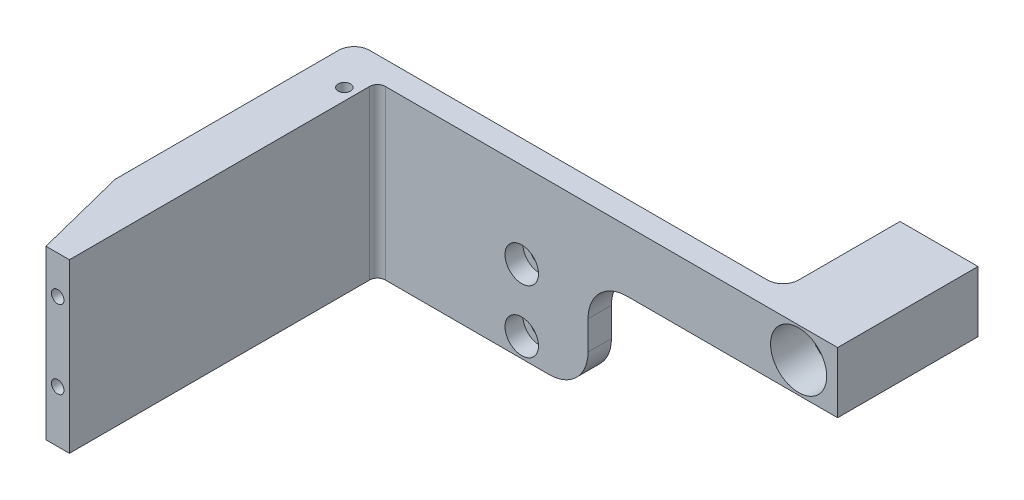
from build123d import *

# Parameters (mm, degrees)
SKETCH_1_W                = 40
SKETCH_1_H                = 10
EXTRUDE_1_DEPTH           = 3
SKETCH_2_W                = 3
SKETCH_2_H                = 10
EXTRUDE_2_DEPTH           = 39.5
EXTRUDE_3_DEPTH           = 10
FILLET_1_R                = 1
SKETCH_4_W                = 40
SKETCH_4_H                = 3
EXTRUDE_4_DEPTH           = 10
HOLE_WIZARD_1_D           = 2.4
HOLE_WIZARD_1_DEPTH       = 3.2
HOLE_WIZARD_1_CBORE_D     = 4.3
HOLE_WIZARD_1_CBORE_DEPTH = 2.3
HOLE_WIZARD_1_TIP         = 0.721032743
HOLE_WIZARD_M2_1_D        = 1.6
HOLE_WIZARD_M2_1_DEPTH    = 5.2
HOLE_WIZARD_M2_1_TIP      = 0.480688495
SKETCH_13_W               = 40
SKETCH_13_H               = 8.5
CUT_EXTRUDE_2_DEPTH       = 10
EXTRUDE_7_DEPTH           = 10
SKETCH_17_W               = 9.259373991
SKETCH_17_H               = 43.053569651
CUT_EXTRUDE_3_DEPTH       = 20
SKETCH_14_W               = 3
SKETCH_14_H               = 7.8
EXTRUDE_8_DEPTH           = 32
SKETCH_18_W               = 10
SKETCH_18_H               = 7.8
EXTRUDE_9_DEPTH           = 15
SKETCH_19_R               = 3.6
CUT_EXTRUDE_4_DEPTH       = 5
HOLE_WIZARD_M4_1_D        = 3.3
FILLET_2_R                = 2
EXTRUDE_10_DEPTH          = 10
EXTRUDE_11_DEPTH          = 1.5
HOLE_WIZARD_M2_2_D        = 1.6
HOLE_WIZARD_M2_2_DEPTH    = 5.2
HOLE_WIZARD_M2_2_TIP      = 0.480688495
HOLE_WIZARD_M2_3_D        = 1.6
HOLE_WIZARD_M2_3_DEPTH    = 5.2
HOLE_WIZARD_M2_3_TIP      = 0.480688495
HOLE_WIZARD_M2_4_D        = 1.6
HOLE_WIZARD_M2_4_DEPTH    = 5.2
HOLE_WIZARD_M2_4_TIP      = 0.480688495
FILLET_3_R                = 2
FILLET_4_R                = 5


with BuildPart() as part:
    # 草图1 → 凸台-拉伸1 (new body)
    with BuildSketch(Plane.XY):
        Rectangle(SKETCH_1_W, SKETCH_1_H)
    extrude(amount=EXTRUDE_1_DEPTH)

    # 草图2 → 凸台-拉伸2 (add)
    with BuildSketch(Plane.XY.offset(3)):
        with Locations((-8.5, 0)):
            Rectangle(SKETCH_2_W, SKETCH_2_H)
    extrude(amount=EXTRUDE_2_DEPTH)

    # 草图3 → 凸台-拉伸3 (add)
    with BuildSketch(Plane(origin=(0, 5, 0), x_dir=(1, 0, 0), z_dir=(0, 1, 0))):
        Polygon((-20, -3), (-10, -42.5), (-10, -30.276150361), (-16.905354522, -3), align=None)
    extrude(amount=-EXTRUDE_3_DEPTH)

    # 圆角1
    fillet_1_edges = [part.edges().sort_by_distance(p)[0] for p in [
        (-7, 0, 3),
    ]]
    fillet(fillet_1_edges, radius=FILLET_1_R)

    # 草图4 → 凸台-拉伸4 (add)
    with BuildSketch(Plane(origin=(0, 5, 0), x_dir=(1, 0, 0), z_dir=(0, 1, 0))):
        with Locations((0, -1.5)):
            Rectangle(SKETCH_4_W, SKETCH_4_H)
    extrude_4 = extrude(amount=EXTRUDE_4_DEPTH)

    # 镜向1: 凸台-拉伸4 across plane
    add(extrude_4.mirror(Plane.ZX))

    # 打孔尺寸(%根据)内六角圆柱头螺钉的类型1
    with Locations(Plane.XY.offset(3)):
        with Locations((11.5, 4), (11.5, -4)):
            CounterBoreHole(HOLE_WIZARD_1_D / 2, HOLE_WIZARD_1_CBORE_D / 2, HOLE_WIZARD_1_CBORE_DEPTH, depth=HOLE_WIZARD_1_DEPTH)
            with Locations((0, 0, -(HOLE_WIZARD_1_DEPTH + HOLE_WIZARD_1_TIP / 2))):  # 118° drill point
                Cone(0, HOLE_WIZARD_1_D / 2, HOLE_WIZARD_1_TIP, mode=Mode.SUBTRACT)

    # M2 螺纹孔1
    with Locations(Plane.XY.offset(42.5)):
        with Locations((-8.5, 0.145727583), (-8.5, 10.145727583)):
            Hole(HOLE_WIZARD_M2_1_D / 2, depth=HOLE_WIZARD_M2_1_DEPTH)
            with Locations((0, 0, -(HOLE_WIZARD_M2_1_DEPTH + HOLE_WIZARD_M2_1_TIP / 2))):  # 118° drill point
                Cone(0, HOLE_WIZARD_M2_1_D / 2, HOLE_WIZARD_M2_1_TIP, mode=Mode.SUBTRACT)

    # 草图13 → 切除-拉伸2 (cut)
    with BuildSketch(Plane(origin=(0, 0, 0), x_dir=(-1, 0, 0), z_dir=(0, 0, -1))):
        with Locations((0, -10.75)):
            Rectangle(SKETCH_13_W, SKETCH_13_H)
    extrude(amount=-CUT_EXTRUDE_2_DEPTH, mode=Mode.SUBTRACT)

    # 草图16 → 凸台-拉伸7 (add)
    with BuildSketch(Plane(origin=(0, 5, 0), x_dir=(1, 0, 0), z_dir=(0, 1, 0))):
        Polygon((-16.905354522, -3), (-10, -30.276150361), (-10, -3), align=None)
    extrude(amount=-EXTRUDE_7_DEPTH)

    # 草图17 → 切除-拉伸3 (cut, symmetric)
    with BuildSketch(Plane(origin=(0, 0, 0), x_dir=(1, 0, 0), z_dir=(0, 1, 0))):
        with Locations((-17.629686996, -17.786551237)):
            Rectangle(SKETCH_17_W, SKETCH_17_H)
    extrude(amount=CUT_EXTRUDE_3_DEPTH, both=True, mode=Mode.SUBTRACT)

    # 草图14 → 凸台-拉伸8 (add)
    with BuildSketch(Plane(origin=(20, 0, 0), x_dir=(0, 0, -1), z_dir=(1, 0, 0))):
        with Locations((-1.5, 11.1)):
            Rectangle(SKETCH_14_W, SKETCH_14_H)
    extrude(amount=EXTRUDE_8_DEPTH)

    # 草图18 → 凸台-拉伸9 (add)
    with BuildSketch(Plane(origin=(0, 0, 0), x_dir=(-1, 0, 0), z_dir=(0, 0, -1))):
        with Locations((-47, 11.1)):
            Rectangle(SKETCH_18_W, SKETCH_18_H)
    extrude(amount=EXTRUDE_9_DEPTH)

    # 草图19 → 切除-拉伸4 (cut)
    with BuildSketch(Plane.XY.offset(3)):
        with Locations((47, 11.1)):
            Circle(SKETCH_19_R)
    extrude(amount=-CUT_EXTRUDE_4_DEPTH, mode=Mode.SUBTRACT)

    # M4 螺纹孔1 (through all)
    with Locations(Plane.XY.offset(-2)):
        with Locations((47, 11.1)):
            Hole(HOLE_WIZARD_M4_1_D / 2)

    # 圆角2
    fillet_2_edges = [part.edges().sort_by_distance(p)[0] for p in [
        (42, 11.1, 0),
    ]]
    fillet(fillet_2_edges, radius=FILLET_2_R)

    # 草图22 → 凸台-拉伸10 (add)
    with BuildSketch(Plane(origin=(0, 5, 0), x_dir=(1, 0, 0), z_dir=(0, 1, 0))):
        with BuildLine():
            Line((-6, -3), (-13, -3))
            Line((-13, -3), (-13, -30.65))
            Line((-13, -30.65), (-10, -42.5))
            Line((-10, -42.5), (-7, -42.5))
            Line((-7, -42.5), (-7, -4))
            ThreePointArc((-7, -4), (-6.707106781, -3.292893219), (-6, -3))
        make_face()
    extrude(amount=EXTRUDE_10_DEPTH)

    # 草图23 → 凸台-拉伸11 (add)
    with BuildSketch(Plane.XZ.offset(5)):
        with BuildLine():
            Line((-10, 42.5), (-13, 30.65))
            Line((-13, 30.65), (-13, 3))
            Line((-13, 3), (-6, 3))
            ThreePointArc((-6, 3), (-6.707106781, 3.292893219), (-7, 4))
            Line((-7, 4), (-7, 42.5))
            Line((-7, 42.5), (-10, 42.5))
        make_face()
    extrude(amount=EXTRUDE_11_DEPTH)

    # M2 螺纹孔2
    with Locations(Plane.XY.offset(42.5)):
        with Locations((-8.5, 10.145727583)):
            Hole(HOLE_WIZARD_M2_2_D / 2, depth=HOLE_WIZARD_M2_2_DEPTH)
            with Locations((0, 0, -(HOLE_WIZARD_M2_2_DEPTH + HOLE_WIZARD_M2_2_TIP / 2))):  # 118° drill point
                Cone(0, HOLE_WIZARD_M2_2_D / 2, HOLE_WIZARD_M2_2_TIP, mode=Mode.SUBTRACT)

    # M2 螺纹孔3
    with Locations(Plane(origin=(0, 15, 0), x_dir=(1, 0, 0), z_dir=(0, 1, 0))):
        with Locations((-8.5, -5.75)):
            Hole(HOLE_WIZARD_M2_3_D / 2, depth=HOLE_WIZARD_M2_3_DEPTH)
            with Locations((0, 0, -(HOLE_WIZARD_M2_3_DEPTH + HOLE_WIZARD_M2_3_TIP / 2))):  # 118° drill point
                Cone(0, HOLE_WIZARD_M2_3_D / 2, HOLE_WIZARD_M2_3_TIP, mode=Mode.SUBTRACT)

    # M2 螺纹孔4
    with Locations(Plane(origin=(0, -6.5, 0), x_dir=(-1, 0, 0), z_dir=(0, -1, 0))):
        with Locations((8.5, -5.75)):
            Hole(HOLE_WIZARD_M2_4_D / 2, depth=HOLE_WIZARD_M2_4_DEPTH)
            with Locations((0, 0, -(HOLE_WIZARD_M2_4_DEPTH + HOLE_WIZARD_M2_4_TIP / 2))):  # 118° drill point
                Cone(0, HOLE_WIZARD_M2_4_D / 2, HOLE_WIZARD_M2_4_TIP, mode=Mode.SUBTRACT)

    # 圆角3
    fillet_3_edges = [part.edges().sort_by_distance(p)[0] for p in [
        (-13, 4.25, 0),
    ]]
    fillet(fillet_3_edges, radius=FILLET_3_R)

    # 圆角4
    fillet_4_edges = [part.edges().sort_by_distance(p)[0] for p in [
        (20, -6.5, 1.5),
        (20, 7.2, 1.5),
    ]]
    fillet(fillet_4_edges, radius=FILLET_4_R)


solid = part.part
